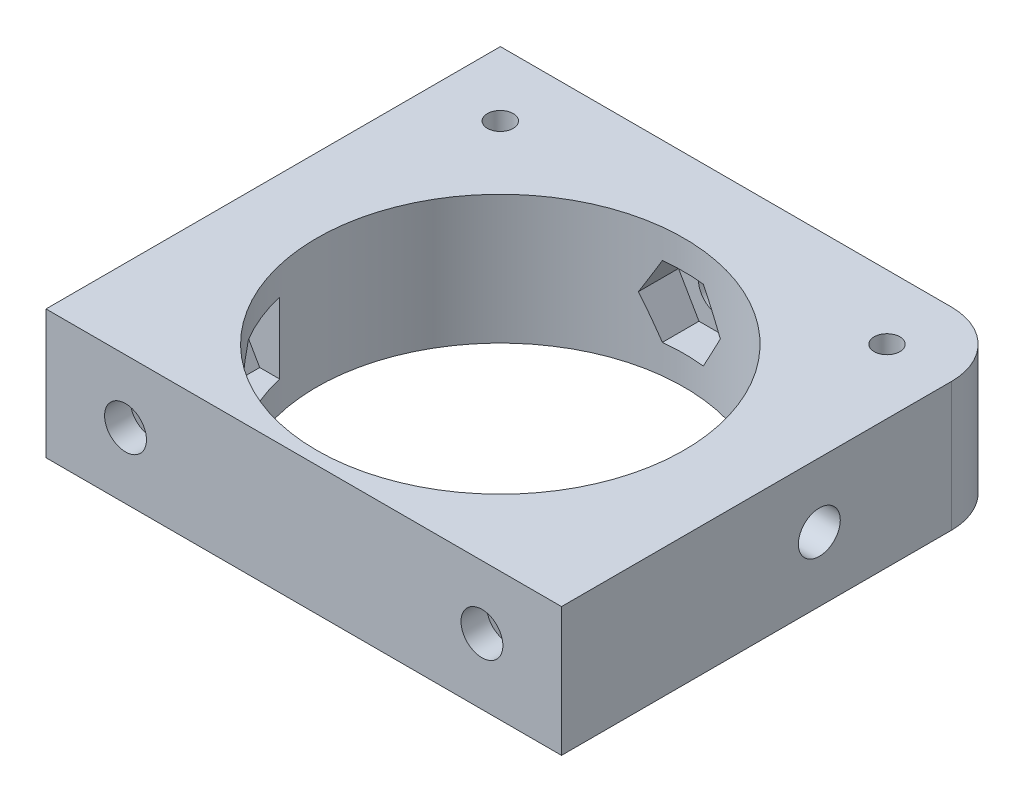
from build123d import *

# Parameters (mm, degrees)
CROQUIS1_R                              = 15.25
CROQUIS1_R_2                            = 2.125
SOPORTE_CAJA_REDUCTORA_DEPTH            = 20
CROQUIS3_R                              = 2.125
CORTAR_EXTRUIR1_DEPTH                   = 51.423828692
REDONDEO1_R                             = 5
BOSS_EXTRUDE1_DEPTH                     = 20
CUT_EXTRUDE1_REACH                      = 55.852
SKETCH2_R                               = 1.625
CUT_EXTRUDE2_DEPTH                      = 2
SKETCH4_R                               = 1.625
CUT_EXTRUDE3_DEPTH                      = 63.291652731
CUT_EXTRUDE4_START                      = -4.5
CUT_EXTRUDE4_DEPTH                      = 2
CROQUIS6_W                              = 4.75
CROQUIS6_H                              = 4.75
CORTAR_EXTRUIR17_DEPTH                  = 42.231056256
CROQUIS7_W                              = 60
CROQUIS7_H                              = 20
CORTAR_EXTRUIR18_DEPTH                  = 51.423828692
SALIENTE_EXTRUIR2_DEPTH                 = 49
SOPORTE_START                           = -15
SOPORTE_MOTOR_DEPTH                     = 15
CROQUIS12_R                             = 2.125
AGUJEROS_DE_SUJECION_A_BASE_DEPTH       = 84.087679592
TUERCA_START                            = -4
TUERCA_AGUJERO_DE_SUJECION_A_BASE_DEPTH = 10
SALIENTE_EXTRUIR4_DEPTH                 = 15
CORTAR_EXTRUIR19_DEPTH                  = 25
CROQUIS14_W                             = 50
CROQUIS14_H                             = 118
CORTAR_EXTRUIR22_DEPTH                  = 146.556045907
CROQUIS15_W                             = 10
CROQUIS15_H                             = 7
CORTAR_EXTRUIR23_DEPTH                  = 42.231056256
CORTAR_EXTRUIR24_DEPTH                  = 42.231056256
CROQUIS18_W                             = 40
CROQUIS18_H                             = 10
CORTAR_EXTRUIR25_DEPTH                  = 44.27311521
SALIENTE_EXTRUIR5_DEPTH                 = 10
CROQUIS20_R                             = 1
CORTAR_EXTRUIR26_DEPTH                  = 49.229270158
CORTAR_EXTRUIR27_REACH                  = 62.959
CORTAR_EXTRUIR27_END_RADIUS             = 15.25
CROQUIS21_R                             = 1.625
CROQUIS22_R                             = 2.125
CROQUIS22_R_2                           = 1
SALIENTE_EXTRUIR6_DEPTH                 = 10
CROQUIS23_R                             = 1.625
CORTAR_EXTRUIR28_DEPTH                  = 52.269508521
CORTAR_EXTRUIR29_START                  = -3
CORTAR_EXTRUIR29_DEPTH                  = 10
SALIENTE_EXTRUIR7_DEPTH                 = 10
CORTAR_EXTRUIR30_REACH                  = 72.235
CROQUIS27_R                             = 1.625
CORTAR_EXTRUIR31_REACH                  = 75.235
CORTAR_EXTRUIR31_START                  = -3
CORTAR_EXTRUIR32_REACH                  = 58.612
CROQUIS29_R                             = 1.625
CORTAR_EXTRUIR33_REACH                  = 61.112
CORTAR_EXTRUIR33_START                  = -2.5
CROQUIS35_W                             = 13.305418987
CROQUIS35_H                             = 6.826864192
CORTAR_EXTRUIR34_DEPTH                  = 63.931555098
CORTAR_EXTRUIR34_DEPTH_BACK             = 63.931555098
CORTAR_EXTRUIR35_START                  = -3
CORTAR_EXTRUIR35_DEPTH                  = 10
SALIENTE_EXTRUIR8_DEPTH                 = 10
SALIENTE_EXTRUIR9_DEPTH                 = 13
SALIENTE_EXTRUIR10_DEPTH                = 3
CROQUIS40_W                             = 106.583537839
CROQUIS40_H                             = 47.391515964
CORTAR_EXTRUIR36_DEPTH                  = 80.887064817
CORTAR_EXTRUIR36_DEPTH_BACK             = 80.887064817
CORTAR_EXTRUIR37_DEPTH                  = 67.2524009
CORTAR_EXTRUIR37_DEPTH_BACK             = 67.2524009
CORTAR_EXTRUIR38_DEPTH                  = 79.704784639
CORTAR_EXTRUIR38_DEPTH_BACK             = 79.704784639
SALIENTE_EXTRUIR11_DEPTH                = 10
CORTAR_EXTRUIR39_DEPTH                  = 63.9908649
CROQUIS45_W                             = 31.470301378
CROQUIS45_H                             = 10
CROQUIS45_R                             = 1.625
SALIENTE_EXTRUIR12_DEPTH                = 2.5
SALIENTE_EXTRUIR13_DEPTH                = 10
CORTAR_EXTRUIR40_START                  = -2
CROQUIS47_R                             = 1.625
CORTAR_EXTRUIR40_DEPTH                  = 10
CORTAR_EXTRUIR41_START                  = -12
CROQUIS48_R                             = 1.625
CORTAR_EXTRUIR41_DEPTH                  = 12
CROQUIS49_W                             = 34.796066513
CROQUIS49_H                             = 42.211026982
CORTAR_EXTRUIR42_DEPTH                  = 52.795622989
CORTAR_EXTRUIR42_DEPTH_BACK             = 52.795622989
CROQUIS51_R                             = 15.25
CROQUIS51_R_2                           = 14.25
SALIENTE_EXTRUIR14_DEPTH                = 10
CORTAR_EXTRUIR43_DEPTH                  = 10
CORTAR_EXTRUIR44_DEPTH                  = 10
CORTAR_EXTRUIR45_DEPTH                  = 10
SALIENTE_EXTRUIR15_DEPTH                = 10


with BuildPart() as part:
    # Croquis1 → Soporte caja reductora (new body)
    with BuildSketch(Plane(origin=(0, 0, 0), x_dir=(1, 0, 0), z_dir=(0, 1, 0))):
        Polygon((-30, -15.25), (-20, -15.25), (-20, -20), (20, -20), (20, -15.25), (30, -15.25), (30, -7.25), (20, -4.25), (20, 20), (-20, 20), (-20, -4.25), (-30, -7.25), align=None)
        with Locations(Location((0, 0, 0), (0, 0, 270))):
            Circle(CROQUIS1_R, mode=Mode.SUBTRACT)
        with Locations(Location((-15, 15, 0), (0, 0, 270))):
            Circle(CROQUIS1_R_2, mode=Mode.SUBTRACT)
        with Locations(Location((15, 15, 0), (0, 0, 270))):
            Circle(CROQUIS1_R_2, mode=Mode.SUBTRACT)
    extrude(amount=-SOPORTE_CAJA_REDUCTORA_DEPTH)

    # Croquis3 → Cortar-Extruir1 (cut, through all)
    with BuildSketch(Plane.XY.offset(15.25)):
        with Locations((-23.5, -10)):
            Circle(CROQUIS3_R)
        with Locations((23.5, -10)):
            Circle(CROQUIS3_R)
    extrude(amount=-CORTAR_EXTRUIR1_DEPTH, mode=Mode.SUBTRACT)

    # Redondeo1
    redondeo1_edges = [part.edges().sort_by_distance(p)[0] for p in [
        (-20, -10, -20),
        (20, -10, -20),
    ]]
    fillet(redondeo1_edges, radius=REDONDEO1_R)

    # Sketch1 → Boss-Extrude1 (add)
    with BuildSketch(Plane(origin=(0, 0, 0), x_dir=(1, 0, 0), z_dir=(0, 1, 0))):
        with BuildLine():
            Line((25.5, 15), (20, 15))
            ThreePointArc((20, 15), (18.535533906, 18.535533906), (15, 20))
            Line((15, 20), (30, 20))
            Line((30, 20), (30, 8))
            Line((30, 8), (25.5, 8))
            Line((25.5, 8), (25.5, 15))
        make_face()
    extrude(amount=-BOSS_EXTRUDE1_DEPTH)

    # Sketch2 → Cut-Extrude1 (cut, up to next)
    with BuildSketch(Plane(origin=(0, 0, -20), x_dir=(-1, 0, 0), z_dir=(0, 0, -1)), mode=Mode.PRIVATE) as cut_extrude1_sk1:
        with Locations((-22.75, -10)):
            Circle(SKETCH2_R)
    cut_extrude1_tool1 = extrude(cut_extrude1_sk1.sketch, amount=-CUT_EXTRUDE1_REACH, mode=Mode.PRIVATE) & part.part
    add(cut_extrude1_tool1.solids().sort_by_distance((22.75, -10, -20))[0], mode=Mode.SUBTRACT)

    # Sketch3 → Cut-Extrude2 (cut)
    with BuildSketch(Plane.XY.offset(-15)):
        Polygon((20, -11.58771324), (22.75, -13.175426481), (25.5, -11.58771324), (25.5, -8.41228676), (22.75, -6.824573519), (20, -8.41228676), align=None)
    extrude(amount=-CUT_EXTRUDE2_DEPTH, mode=Mode.SUBTRACT)

    # Sketch4 → Cut-Extrude3 (cut, through all)
    with BuildSketch(Plane.ZY.offset(-25.5)):
        with Locations((-12.25, -10)):
            Circle(SKETCH4_R)
    extrude(amount=-CUT_EXTRUDE3_DEPTH, mode=Mode.SUBTRACT)

    # Sketch5 → Cut-Extrude4 (cut)
    with BuildSketch(Plane(origin=(30, 0, 0), x_dir=(0, 0, -1), z_dir=(1, 0, 0)).offset(CUT_EXTRUDE4_START)):
        Polygon((15, -11.58771324), (15, -8.41228676), (12.25, -6.824573519), (9.5, -8.41228676), (9.5, -11.58771324), (12.25, -13.175426481), align=None)
    extrude(amount=CUT_EXTRUDE4_DEPTH, mode=Mode.SUBTRACT)

    # Croquis6 → Cortar-Extruir17 (cut, through all)
    with BuildSketch(Plane(origin=(0, 0, 0), x_dir=(1, 0, 0), z_dir=(0, 1, 0))):
        Polygon((0, -15.25), (-15.25, -15.25), (-15.25, -20), (15.25, -20), (15.25, -15.25), align=None)
        with Locations((-17.625, -17.625)):
            Rectangle(CROQUIS6_W, CROQUIS6_H)
        with BuildLine():
            ThreePointArc((0, -15.25), (-10.783378413, -10.783378413), (-15.25, 0))
            Line((-15.25, 0), (-15.25, -15.25))
            Line((-15.25, -15.25), (0, -15.25))
        make_face()
        with BuildLine():
            Line((15.25, -15.25), (15.25, 0))
            ThreePointArc((15.25, 0), (10.783378413, -10.783378413), (0, -15.25))
            Line((0, -15.25), (15.25, -15.25))
        make_face()
        with Locations((17.625, -17.625)):
            Rectangle(CROQUIS6_W, CROQUIS6_H)
    extrude(amount=-CORTAR_EXTRUIR17_DEPTH, mode=Mode.SUBTRACT)


with BuildPart() as body_2:
    # Simetría1: mirrored copy
    add(part.part.mirror(Plane.ZX))

    # Croquis8 → Saliente-Extruir2 (add)
    with BuildSketch(Plane(origin=(0, 20, 0), x_dir=(1, 0, 0), z_dir=(0, 1, 0))):
        with BuildLine():
            Line((-12.664515522, 20), (-11.040489496, 13.939052358))
            Line((-11.040489496, 13.939052358), (-10.315162126, 11.232093763))
            ThreePointArc((-10.315162126, 11.232093763), (0, 15.25), (10.315162126, 11.232093763))
            Line((10.315162126, 11.232093763), (10.817418481, 13.87928066))
            Line((10.817418481, 13.87928066), (11.978715476, 20))
            Line((11.978715476, 20), (-12.664515522, 20))
        make_face()
    extrude(amount=SALIENTE_EXTRUIR2_DEPTH)

    # Croquis9 → Soporte motor (add)
    with BuildSketch(Plane(origin=(0, 69, 0), x_dir=(1, 0, 0), z_dir=(0, 1, 0)).offset(SOPORTE_START)):
        with BuildLine():
            Line((-20, 15), (-20, -4.25))
            Line((-20, -4.25), (-30, -7.25))
            Line((-30, -7.25), (-30, -15.25))
            Line((-30, -15.25), (0, -15.25))
            Line((0, -15.25), (0, -14.75))
            ThreePointArc((0, -14.75), (-10.429825023, 10.429825023), (14.75, 0))
            Line((14.75, 0), (20, 0))
            Line((20, 0), (20, 13.936837101))
            Line((20, 13.936837101), (12.664515522, 20))
            Line((12.664515522, 20), (-15, 20))
            ThreePointArc((-15, 20), (-18.535533906, 18.535533906), (-20, 15))
        make_face()
    extrude(amount=-SOPORTE_MOTOR_DEPTH)

    # Croquis12 → Agujeros de sujecion a base (cut, through all)
    with BuildSketch(Plane.XY.offset(15.25)):
        with Locations((-23.5, 46.5)):
            Circle(CROQUIS12_R)
    extrude(amount=-AGUJEROS_DE_SUJECION_A_BASE_DEPTH, mode=Mode.SUBTRACT)

    # Croquis13 → Tuerca Agujero de sujecion a base (cut)
    with BuildSketch(Plane.XY.offset(15.25).offset(TUERCA_START)):
        Polygon((-20, 44.479274058), (-20, 48.520725942), (-23.5, 50.541451884), (-27, 48.520725942), (-27, 44.479274058), (-23.5, 42.458548116), align=None)
    extrude(amount=-TUERCA_AGUJERO_DE_SUJECION_A_BASE_DEPTH, mode=Mode.SUBTRACT)

    # Croquis10 → Saliente-Extruir4 (add)
    with BuildSketch(Plane(origin=(0, 69, 0), x_dir=(1, 0, 0), z_dir=(0, 1, 0))):
        with BuildLine():
            ThreePointArc((10.315162126, 11.232093763), (0, 15.25), (-10.315162126, 11.232093763))
            Line((-10.315162126, 11.232093763), (-10.16850369, 10.684757026))
            ThreePointArc((-10.16850369, 10.684757026), (0, 14.75), (10.16850369, 10.684757026))
            Line((10.16850369, 10.684757026), (10.315162126, 11.232093763))
        make_face()
    extrude(amount=-SALIENTE_EXTRUIR4_DEPTH)

    # Croquis11 → Cortar-Extruir19 (cut)
    with BuildSketch(Plane.XZ):
        with BuildLine():
            Line((15.25, 4.25), (20, 4.25))
            Line((20, 4.25), (21.972856468, 4.84185694))
            ThreePointArc((21.972856468, 4.84185694), (19.948931102, 10.40625523), (16.543503257, 15.25))
            Line((16.543503257, 15.25), (15.25, 15.25))
            Line((15.25, 15.25), (15.25, 4.25))
        make_face()
        with BuildLine():
            Line((21.972856468, 4.84185694), (30, 7.25))
            Line((30, 7.25), (30, 15.25))
            Line((30, 15.25), (16.543503257, 15.25))
            ThreePointArc((16.543503257, 15.25), (19.948931102, 10.40625523), (21.972856468, 4.84185694))
        make_face()
        with BuildLine():
            ThreePointArc((20, -15), (18.535533906, -18.535533906), (15, -20))
            Line((15, -20), (30, -20))
            Line((30, -20), (30, -8))
            Line((30, -8), (25.5, -8))
            Line((25.5, -8), (25.5, -15))
            Line((25.5, -15), (20, -15))
        make_face()
    extrude(amount=-CORTAR_EXTRUIR19_DEPTH, mode=Mode.SUBTRACT)

    # Simetría2: body 2 across face


with BuildPart() as part_1:
    add(part.part)

    # Croquis7 → Cortar-Extruir18 (cut, through all)
    with BuildSketch(Plane(origin=(0, 0, -20), x_dir=(-1, 0, 0), z_dir=(0, 0, -1))):
        with Locations((0, -10)):
            Rectangle(CROQUIS7_W, CROQUIS7_H)
    extrude(amount=-CORTAR_EXTRUIR18_DEPTH, mode=Mode.SUBTRACT)


with BuildPart() as body_2_1:
    add(body_2.part)
    add(body_2.part.mirror(Plane(origin=(-0.229209569, 69, -16.663998028), x_dir=(0, 0, 1), z_dir=(0, 1, 0))))

    # Croquis14 → Cortar-Extruir22 (cut, through all)
    with BuildSketch(Plane.XY.offset(15.25)):
        with Locations((-5, 79)):
            Rectangle(CROQUIS14_W, CROQUIS14_H)
    extrude(amount=-CORTAR_EXTRUIR22_DEPTH, mode=Mode.SUBTRACT)

    # Croquis15 → Cortar-Extruir23 (cut, through all)
    with BuildSketch(Plane.XZ):
        with Locations((-25, 7.75)):
            Rectangle(CROQUIS15_W, CROQUIS15_H)
    extrude(amount=-CORTAR_EXTRUIR23_DEPTH, mode=Mode.SUBTRACT)

    # Croquis16 → Cortar-Extruir24 (cut, through all)
    with BuildSketch(Plane.XZ):
        Polygon((-30, 15.25), (-15.25, 15.25), (-15.25, 12.75), (-20, 12.75), (-20, 11.25), (-30, 11.25), (-30, 12.75), align=None)
    extrude(amount=-CORTAR_EXTRUIR24_DEPTH, mode=Mode.SUBTRACT)

    # Croquis18 → Cortar-Extruir25 (cut, through all)
    with BuildSketch(Plane(origin=(0, 0, -20), x_dir=(-1, 0, 0), z_dir=(0, 0, -1))):
        with Locations((0, 5)):
            Rectangle(CROQUIS18_W, CROQUIS18_H)
    extrude(amount=-CORTAR_EXTRUIR25_DEPTH, mode=Mode.SUBTRACT)

    # Croquis19 → Saliente-Extruir5 (add)
    with BuildSketch(Plane(origin=(0, 20, 0), x_dir=(1, 0, 0), z_dir=(0, 1, 0))):
        Polygon((-20, -12.75), (-34, -12.75), (-34, -7.75), (-24, -7.75), (-20, -3.75), align=None)
    extrude(amount=-SALIENTE_EXTRUIR5_DEPTH)

    # Croquis20 → Cortar-Extruir26 (cut, through all)
    with BuildSketch(Plane(origin=(0, 0, 7.75), x_dir=(-1, 0, 0), z_dir=(0, 0, -1))):
        with Locations((29, 15)):
            Circle(CROQUIS20_R)
    extrude(amount=-CORTAR_EXTRUIR26_DEPTH, mode=Mode.SUBTRACT)

    # Cortar-Extruir27: up to this cylinder (the profile starts outside it)
    cortar_extruir27_end = Plane(origin=(0, 15, 0), z_dir=(0, -1, 0)) * Cylinder(CORTAR_EXTRUIR27_END_RADIUS, 157.418, mode=Mode.PRIVATE)
    # Croquis21 → Cortar-Extruir27 (cut, up to the surface)
    with BuildSketch(Plane(origin=(20, 0, 0), x_dir=(0, 0, -1), z_dir=(1, 0, 0)), mode=Mode.PRIVATE) as cortar_extruir27_sk1:
        with Locations((4.75, 15)):
            Circle(CROQUIS21_R)
    cortar_extruir27_tool1 = extrude(cortar_extruir27_sk1.sketch, amount=-CORTAR_EXTRUIR27_REACH, mode=Mode.PRIVATE) - cortar_extruir27_end
    add(cortar_extruir27_tool1.solids().sort_by_distance((20, 15, -4.75))[0], mode=Mode.SUBTRACT)

    # Croquis22 → Saliente-Extruir6 (add)
    with BuildSketch(Plane.XZ.offset(-10)):
        with Locations((-15, -15)):
            Circle(CROQUIS22_R)
        with Locations(Location((-15, -15, 0), (0, 0, 270))):
            Circle(CROQUIS22_R_2, mode=Mode.SUBTRACT)
        with Locations((15, -15)):
            Circle(CROQUIS22_R)
        with Locations(Location((15, -15, 0), (0, 0, 270))):
            Circle(CROQUIS22_R_2, mode=Mode.SUBTRACT)
    extrude(amount=-SALIENTE_EXTRUIR6_DEPTH)

    # Croquis23 → Cortar-Extruir28 (cut, through all)
    with BuildSketch(Plane(origin=(0, 0, -20), x_dir=(-1, 0, 0), z_dir=(0, 0, -1))):
        with Locations((0, 15)):
            Circle(CROQUIS23_R)
    extrude(amount=-CORTAR_EXTRUIR28_DEPTH, mode=Mode.SUBTRACT)

    # Croquis24 → Cortar-Extruir29 (cut)
    with BuildSketch(Plane(origin=(0, 0, -20), x_dir=(-1, 0, 0), z_dir=(0, 0, -1)).offset(CORTAR_EXTRUIR29_START)):
        Polygon((1.58771324, 12.25), (3.175426481, 15), (1.58771324, 17.75), (-1.58771324, 17.75), (-3.175426481, 15), (-1.58771324, 12.25), align=None)
    extrude(amount=-CORTAR_EXTRUIR29_DEPTH, mode=Mode.SUBTRACT)

    # Croquis26 → Saliente-Extruir7 (add)
    with BuildSketch(Plane.XZ.offset(-10)):
        Polygon((-34, 7.75), (-34, 12.75), (-58.825, 12.75), (-39.160527763, -4.104491148), (-20, -4.104491148), (-20, -0.104491148), (-35.732113118, -0.104491148), (-29, 7.75), align=None)
        Polygon((-34.268209086, 7.75), (-39.594516123, 1.535690951), (-46.844874897, 7.75), align=None, mode=Mode.SUBTRACT)
    extrude(amount=-SALIENTE_EXTRUIR7_DEPTH)

    # Croquis27 → Cortar-Extruir30 (cut, up to next)
    with BuildSketch(Plane.XY.offset(12.75), mode=Mode.PRIVATE) as cortar_extruir30_sk1:
        with Locations((-40.544874897, 15)):
            Circle(CROQUIS27_R)
    cortar_extruir30_tool1 = extrude(cortar_extruir30_sk1.sketch, amount=-CORTAR_EXTRUIR30_REACH, mode=Mode.PRIVATE) & body_2_1.part
    # Croquis27 → Cortar-Extruir30 (cut, up to next)
    with BuildSketch(Plane.XY.offset(12.75), mode=Mode.PRIVATE) as cortar_extruir30_sk2:
        with Locations((-29, 15)):
            Circle(CROQUIS27_R)
    cortar_extruir30_tool2 = extrude(cortar_extruir30_sk2.sketch, amount=-CORTAR_EXTRUIR30_REACH, mode=Mode.PRIVATE) & body_2_1.part
    add(cortar_extruir30_tool1.solids().sort_by_distance((-40.544875, 15, 12.75))[0], mode=Mode.SUBTRACT)
    add(cortar_extruir30_tool2.solids().sort_by_distance((-29, 15, 12.75))[0], mode=Mode.SUBTRACT)

    # Croquis28 → Cortar-Extruir31 (cut, up to next)
    with BuildSketch(Plane.XY.offset(12.75).offset(CORTAR_EXTRUIR31_START), mode=Mode.PRIVATE) as cortar_extruir31_sk1:
        Polygon((-38.957161657, 12.25), (-37.369448416, 15), (-38.957161657, 17.75), (-42.132588137, 17.75), (-43.720301378, 15), (-42.132588137, 12.25), align=None)
    cortar_extruir31_tool1 = extrude(cortar_extruir31_sk1.sketch, amount=-CORTAR_EXTRUIR31_REACH, mode=Mode.PRIVATE) & body_2_1.part
    # Croquis28 → Cortar-Extruir31 (cut, up to next)
    with BuildSketch(Plane.XY.offset(12.75).offset(CORTAR_EXTRUIR31_START), mode=Mode.PRIVATE) as cortar_extruir31_sk2:
        Polygon((-27.41228676, 12.25), (-25.824573519, 15), (-27.41228676, 17.75), (-30.58771324, 17.75), (-32.175426481, 15), (-30.58771324, 12.25), align=None)
    cortar_extruir31_tool2 = extrude(cortar_extruir31_sk2.sketch, amount=-CORTAR_EXTRUIR31_REACH, mode=Mode.PRIVATE) & body_2_1.part
    add(cortar_extruir31_tool1.solids().sort_by_distance((-40.544875, 15, 9.75))[0], mode=Mode.SUBTRACT)
    add(cortar_extruir31_tool2.solids().sort_by_distance((-29, 15, 9.75))[0], mode=Mode.SUBTRACT)

    # Croquis29 → Cortar-Extruir32 (cut, up to next)
    with BuildSketch(Plane(origin=(-18.612848159, 0, -21.715982563), x_dir=(-0.7592713073348843, 0, 0.6507742172658468), z_dir=(-0.6507742172658468, 0, -0.7592713073348843)), mode=Mode.PRIVATE) as cortar_extruir32_sk1:
        with Locations((33.812368097, 15)):
            Circle(CROQUIS29_R)
    cortar_extruir32_tool1 = extrude(cortar_extruir32_sk1.sketch, amount=-CORTAR_EXTRUIR32_REACH, mode=Mode.PRIVATE) & body_2_1.part
    add(cortar_extruir32_tool1.solids().sort_by_distance((-44.285609, 15, 0.288235))[0], mode=Mode.SUBTRACT)

    # Croquis31 → Cortar-Extruir33 (cut, up to next)
    with BuildSketch(Plane(origin=(-18.612848159, 0, -21.715982563), x_dir=(-0.7592713073348843, 0, 0.6507742172658468), z_dir=(-0.6507742172658468, 0, -0.7592713073348843)).offset(CORTAR_EXTRUIR33_START), mode=Mode.PRIVATE) as cortar_extruir33_sk1:
        Polygon((36.562368097, 16.58771324), (33.812368097, 18.175426481), (31.062368097, 16.58771324), (31.062368097, 13.41228676), (33.812368097, 11.824573519), (36.562368097, 13.41228676), align=None)
    cortar_extruir33_tool1 = extrude(cortar_extruir33_sk1.sketch, amount=-CORTAR_EXTRUIR33_REACH, mode=Mode.PRIVATE) & body_2_1.part
    add(cortar_extruir33_tool1.solids().sort_by_distance((-42.658674, 15, 2.186413))[0], mode=Mode.SUBTRACT)

    # Croquis35 → Cortar-Extruir34 (cut, two sides)
    with BuildSketch(Plane(origin=(0, 20, 0), x_dir=(1, 0, 0), z_dir=(0, 1, 0))) as cortar_extruir34_sk:
        with Locations((17.04227466, -3.413432096)):
            Rectangle(CROQUIS35_W, CROQUIS35_H)
    extrude(amount=CORTAR_EXTRUIR34_DEPTH, mode=Mode.SUBTRACT)
    extrude(cortar_extruir34_sk.sketch, amount=-CORTAR_EXTRUIR34_DEPTH_BACK, mode=Mode.SUBTRACT)

    # Croquis36 → Cortar-Extruir35 (cut)
    with BuildSketch(Plane(origin=(20, 0, 0), x_dir=(0, 0, -1), z_dir=(1, 0, 0)).offset(CORTAR_EXTRUIR35_START)):
        Polygon((7.5, 16.58771324), (4.75, 18.175426481), (2, 16.58771324), (2, 13.41228676), (4.75, 11.824573519), (7.5, 13.41228676), align=None)
    extrude(amount=-CORTAR_EXTRUIR35_DEPTH, mode=Mode.SUBTRACT)

    # Croquis37 → Saliente-Extruir8 (add)
    with BuildSketch(Plane.XZ.offset(-10)):
        Polygon((-39.160527763, -4.104491148), (-20.614919368, -20), (-15, -20), (-19.558128305, -15.637570403), (-33.014002756, -4.104491148), align=None)
    extrude(amount=-SALIENTE_EXTRUIR8_DEPTH)

    # Croquis38 → Saliente-Extruir9 (add)
    with BuildSketch(Plane.XZ.offset(-10)):
        Polygon((-58.825, 12.75), (-38.825, 12.75), (-38.825, 9.75), (-55.324839942, 9.75), align=None)
    extrude(amount=SALIENTE_EXTRUIR9_DEPTH)

    # Croquis39 → Saliente-Extruir10 (add)
    with BuildSketch(Plane.XZ.offset(-10)):
        Polygon((-38.825, 9.75), (-38.825, 7.75), (-38.825, 5.75), (-50.657959865, 5.75), (-52.991399903, 7.75), (-55.324839942, 9.75), align=None)
    extrude(amount=SALIENTE_EXTRUIR10_DEPTH)

    # Simetría3: body 2 across face


with BuildPart() as body_2_2:
    add(body_2_1.part)
    add(body_2_1.part.mirror(Plane(origin=(-18.003999227, 20, -4.220503046), x_dir=(0, 0, 1), z_dir=(0, 1, 0))))

    # Croquis40 → Cortar-Extruir36 (cut, two sides)
    with BuildSketch(Plane(origin=(0, 0, -20), x_dir=(-1, 0, 0), z_dir=(0, 0, -1))) as cortar_extruir36_sk:
        with Locations((22.395502026, -3.695757982)):
            Rectangle(CROQUIS40_W, CROQUIS40_H)
    extrude(amount=CORTAR_EXTRUIR36_DEPTH, mode=Mode.SUBTRACT)
    extrude(cortar_extruir36_sk.sketch, amount=-CORTAR_EXTRUIR36_DEPTH_BACK, mode=Mode.SUBTRACT)

    # Croquis41 → Cortar-Extruir37 (cut, two sides)
    with BuildSketch(Plane.XZ.offset(-20)) as cortar_extruir37_sk:
        Polygon((-19.992980133, -22.302484261), (-20, 3.75), (-24, 7.75), (-56.035110209, 7.75), align=None)
    extrude(amount=CORTAR_EXTRUIR37_DEPTH, mode=Mode.SUBTRACT)
    extrude(cortar_extruir37_sk.sketch, amount=-CORTAR_EXTRUIR37_DEPTH_BACK, mode=Mode.SUBTRACT)

    # Croquis42 → Cortar-Extruir38 (cut, two sides)
    with BuildSketch(Plane(origin=(0, 0, 9.75), x_dir=(-1, 0, 0), z_dir=(0, 0, -1))) as cortar_extruir38_sk:
        Polygon((46.720301378, 20), (46.720301378, 30), (38.825, 30), (33.492952769, 43.760628779), (49.525340398, 48.951442806), (67.200390695, 42.512205152), (65.906601328, 20), (51.713995885, 13.864168239), align=None)
    extrude(amount=CORTAR_EXTRUIR38_DEPTH, mode=Mode.SUBTRACT)
    extrude(cortar_extruir38_sk.sketch, amount=-CORTAR_EXTRUIR38_DEPTH_BACK, mode=Mode.SUBTRACT)

    # Croquis43 → Saliente-Extruir11 (add)
    with BuildSketch(Plane.XZ.offset(-20)):
        Polygon((-19.993600539, -20), (-46.720301378, 7.75), (-43.839252857, 10.524807997), (-17.112552018, -17.225192003), align=None)
    extrude(amount=-SALIENTE_EXTRUIR11_DEPTH)

    # Croquis44 → Cortar-Extruir39 (cut, through all)
    with BuildSketch(Plane(origin=(0, 0, 9.75), x_dir=(-1, 0, 0), z_dir=(0, 0, -1))):
        Polygon((38.957161657, 27.75), (37.369448416, 25), (38.957161657, 22.25), (42.132588137, 22.25), (43.720301378, 25), (42.132588137, 27.75), align=None)
    extrude(amount=CORTAR_EXTRUIR39_DEPTH, mode=Mode.SUBTRACT)

    # Croquis45 → Saliente-Extruir12 (add)
    with BuildSketch(Plane.XY.offset(12.75)):
        with Locations((-30.985150689, 25)):
            Rectangle(CROQUIS45_W, CROQUIS45_H)
        with Locations((-40.544874897, 25)):
            Circle(CROQUIS45_R, mode=Mode.SUBTRACT)
        with Locations((-29, 25)):
            Circle(CROQUIS45_R, mode=Mode.SUBTRACT)
    extrude(amount=SALIENTE_EXTRUIR12_DEPTH)

    # Croquis46 → Saliente-Extruir13 (add)
    with BuildSketch(Plane.XZ.offset(-20)):
        with BuildLine():
            Line((15.25, 0), (20, 0))
            Line((20, 0), (20, 15.25))
            Line((20, 15.25), (7.549834435, 15.25))
            Line((7.549834435, 15.25), (7.549834435, 13.25))
            ThreePointArc((7.549834435, 13.25), (13.185171124, 7.662490615), (15.25, 0))
        make_face()
        with BuildLine():
            Line((-15.25, 0), (-15.25, 15.25))
            Line((-15.25, 15.25), (-7.549834435, 15.25))
            Line((-7.549834435, 15.25), (-7.549834435, 13.25))
            ThreePointArc((-7.549834435, 13.25), (-13.185171124, 7.662490615), (-15.25, 0))
        make_face()
    extrude(amount=-SALIENTE_EXTRUIR13_DEPTH)

    # Croquis47 → Cortar-Extruir40 (cut)
    with BuildSketch(Plane.XY.offset(15.25).offset(CORTAR_EXTRUIR40_START)):
        Polygon((15.41228676, 22.352505966), (17, 25.102505966), (15.41228676, 27.852505966), (12.236860279, 27.852505966), (10.649147039, 25.102505966), (12.236860279, 22.352505966), align=None)
        with Locations((13.824573519, 25.102505966)):
            Circle(CROQUIS47_R, mode=Mode.SUBTRACT)
        Polygon((-12.236860279, 22.352505966), (-15.41228676, 22.352505966), (-17, 25.102505966), (-15.41228676, 27.852505966), (-12.236860279, 27.852505966), (-10.649147039, 25.102505966), align=None)
        with Locations(Location((-13.824573519, 25.102505966, 0), (0, 0, 131.421584744))):
            Circle(CROQUIS47_R, mode=Mode.SUBTRACT)
    extrude(amount=-CORTAR_EXTRUIR40_DEPTH, mode=Mode.SUBTRACT)

    # Croquis48 → Cortar-Extruir41 (cut)
    with BuildSketch(Plane.XY.offset(15.25).offset(CORTAR_EXTRUIR41_START)):
        with Locations((13.824573519, 25.102505966)):
            Circle(CROQUIS48_R)
        with Locations((-13.824573519, 25.102505966)):
            Circle(CROQUIS48_R)
    extrude(amount=CORTAR_EXTRUIR41_DEPTH, mode=Mode.SUBTRACT)

    # Croquis49 → Cortar-Extruir42 (cut, two sides)
    with BuildSketch(Plane.XZ.offset(-20)) as cortar_extruir42_sk:
        with Locations((-37.391633796, 1.105513491)):
            Rectangle(CROQUIS49_W, CROQUIS49_H)
    extrude(amount=CORTAR_EXTRUIR42_DEPTH, mode=Mode.SUBTRACT)
    extrude(cortar_extruir42_sk.sketch, amount=-CORTAR_EXTRUIR42_DEPTH_BACK, mode=Mode.SUBTRACT)

    # Croquis51 → Saliente-Extruir14 (add)
    with BuildSketch(Plane(origin=(0, 30, 0), x_dir=(1, 0, 0), z_dir=(0, 1, 0))):
        Circle(CROQUIS51_R)
        with Locations(Location((0, 0, 0), (0, 0, 270))):
            Circle(CROQUIS51_R_2, mode=Mode.SUBTRACT)
    extrude(amount=-SALIENTE_EXTRUIR14_DEPTH)

    # Croquis52 → Cortar-Extruir43 (cut)
    with BuildSketch(Plane(origin=(0, 0, 13.25), x_dir=(-1, 0, 0), z_dir=(0, 0, -1))):
        Polygon((-10.649147039, 25.102505966), (-12.236860279, 27.852505966), (-15.41228676, 27.852505966), (-17, 25.102505966), (-15.41228676, 22.352505966), (-12.236860279, 22.352505966), align=None)
        Polygon((17, 25.102505966), (15.41228676, 27.852505966), (12.236860279, 27.852505966), (10.649147039, 25.102505966), (12.236860279, 22.352505966), (15.41228676, 22.352505966), align=None)
    extrude(amount=CORTAR_EXTRUIR43_DEPTH, mode=Mode.SUBTRACT)

    # Croquis53 → Cortar-Extruir44 (cut)
    with BuildSketch(Plane.XY.offset(-17)):
        Polygon((3.175426481, 25), (1.58771324, 27.75), (-1.58771324, 27.75), (-3.175426481, 25), (-1.58771324, 22.25), (1.58771324, 22.25), align=None)
    extrude(amount=CORTAR_EXTRUIR44_DEPTH, mode=Mode.SUBTRACT)

    # Croquis54 → Cortar-Extruir45 (cut)
    with BuildSketch(Plane.ZY.offset(-17)):
        Polygon((-4.75, 28.175426481), (-7.5, 26.58771324), (-7.5, 23.41228676), (-4.75, 21.824573519), (-2, 23.41228676), (-2, 26.58771324), align=None)
    extrude(amount=CORTAR_EXTRUIR45_DEPTH, mode=Mode.SUBTRACT)

    # Croquis55 → Saliente-Extruir15 (add)
    with BuildSketch(Plane(origin=(0, 30, 0), x_dir=(1, 0, 0), z_dir=(0, 1, 0))):
        with BuildLine():
            Line((-7.549834435, -13.25), (-7.549834435, -15.25))
            Line((-7.549834435, -15.25), (0, -15.25))
            ThreePointArc((0, -15.25), (-3.905124838, -14.741522988), (-7.549834435, -13.25))
        make_face()
        with BuildLine():
            ThreePointArc((7.549834435, -13.25), (3.905124838, -14.741522988), (0, -15.25))
            Line((0, -15.25), (7.549834435, -15.25))
            Line((7.549834435, -15.25), (7.549834435, -13.25))
        make_face()
    extrude(amount=-SALIENTE_EXTRUIR15_DEPTH)


solid = body_2_2.part
